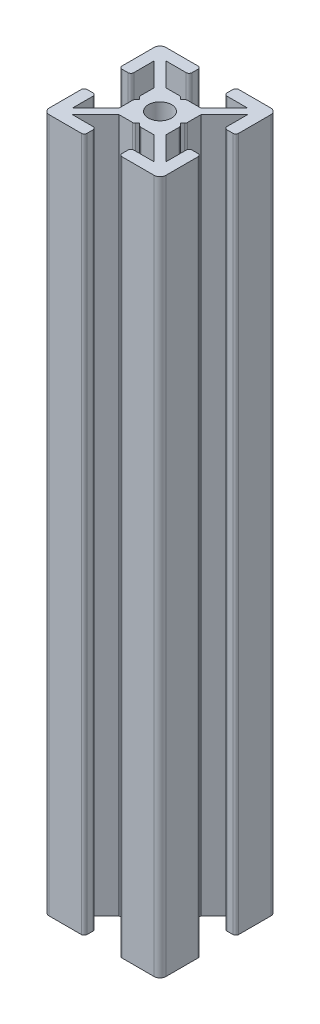
from build123d import *

# Parameters (mm, degrees)
SKETCH1_R           = 2
BOSS_EXTRUDE1_DEPTH = 119
FILLET1_R           = 1
FILLET2_R           = 0.5
FILLET4_R           = 0.5


with BuildPart() as part:
    # Sketch1 → Boss-Extrude1 (new body)
    with BuildSketch(Plane(origin=(0, 0, 0), x_dir=(1, 0, 0), z_dir=(0, 1, 0))):
        Polygon((7, 18), (7, 20), (0, 20), (0, 13), (2, 13), (2, 17), (6, 13), (6, 10.5), (6.5, 10), (6, 9.5), (6, 7), (2, 3), (2, 7), (0, 7), (0, 0), (7, 0), (7, 2), (3, 2), (7, 6), (9.5, 6), (10, 6.5), (10.5, 6), (13, 6), (17, 2), (13, 2), (13, 0), (20, 0), (20, 7), (18, 7), (18, 3), (14, 7), (14, 9.5), (13.5, 10), (14, 10.5), (14, 13), (18, 17), (18, 13), (20, 13), (20, 20), (13, 20), (13, 18), (17, 18), (13, 14), (10.5, 14), (10, 13.5), (9.5, 14), (7, 14), (3, 18), align=None)
        with Locations((10, 10)):
            Circle(SKETCH1_R, mode=Mode.SUBTRACT)
    extrude(amount=BOSS_EXTRUDE1_DEPTH)

    # Fillet1
    fillet1_edges = [part.edges().sort_by_distance(p)[0] for p in [
        (20, 59.5, 0),
        (0, 59.5, 0),
        (0, 59.5, -20),
        (20, 59.5, -20),
    ]]
    fillet(fillet1_edges, radius=FILLET1_R)

    # Fillet2
    fillet2_edges = [part.edges().sort_by_distance(p)[0] for p in [
        (18, 59.5, -7),
        (20, 59.5, -7),
        (13, 59.5, 0),
        (13, 59.5, -2),
        (7, 59.5, -2),
        (7, 59.5, 0),
        (0, 59.5, -7),
        (2, 59.5, -7),
        (2, 59.5, -13),
        (0, 59.5, -13),
        (7, 59.5, -20),
        (7, 59.5, -18),
        (13, 59.5, -18),
        (13, 59.5, -20),
        (20, 59.5, -13),
        (18, 59.5, -13),
    ]]
    fillet(fillet2_edges, radius=FILLET2_R)

    # Fillet4
    fillet4_edges = [part.edges().sort_by_distance(p)[0] for p in [
        (10.5, 59.5, -6),
        (9.5, 59.5, -6),
        (6, 59.5, -9.5),
        (6, 59.5, -10.5),
        (9.5, 59.5, -14),
        (10.5, 59.5, -14),
        (14, 59.5, -10.5),
        (14, 59.5, -9.5),
    ]]
    fillet(fillet4_edges, radius=FILLET4_R)


solid = part.part
